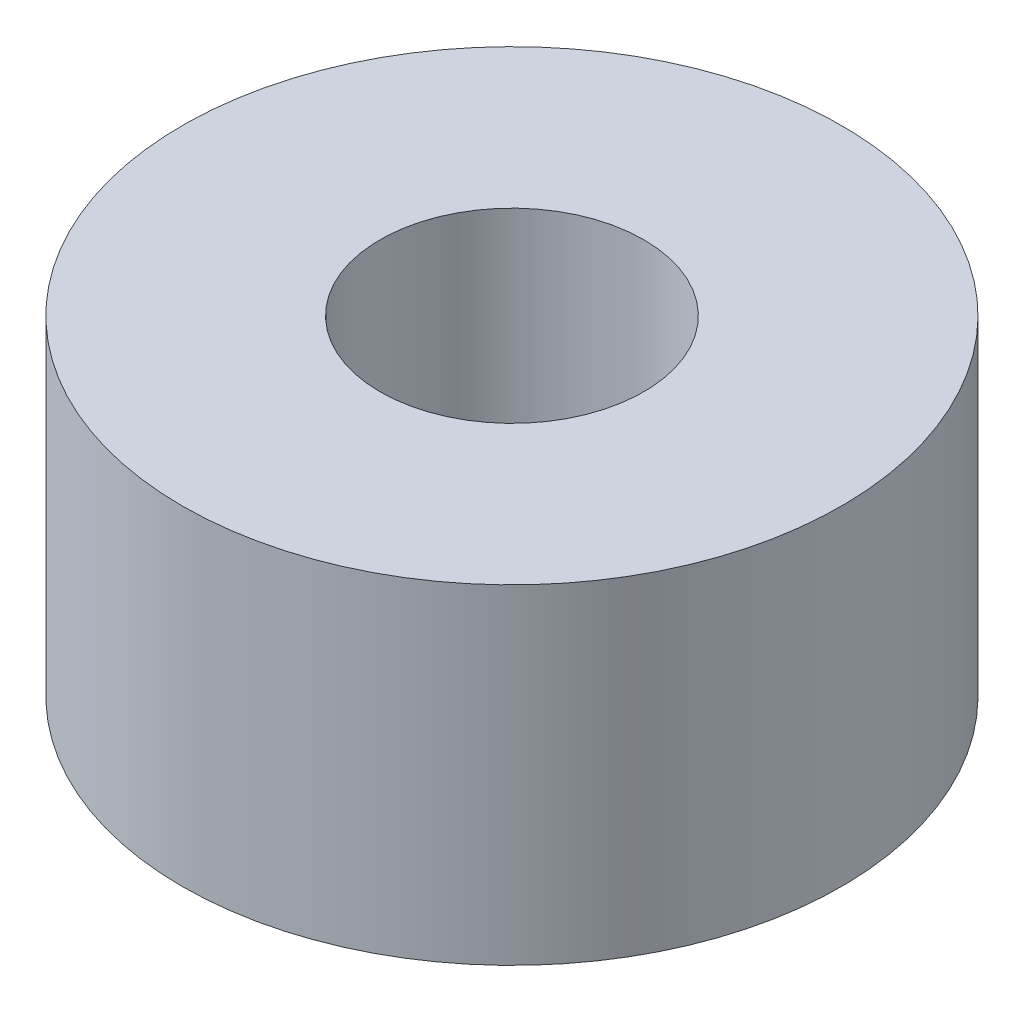
from build123d import *

# Parameters (mm, degrees)
SKETCH_1_R      = 2.5
SKETCH_1_R_2    = 1
EXTRUDE_1_DEPTH = 2.5


with BuildPart() as part:
    # 草图1 → 凸台-拉伸1 (new body)
    with BuildSketch(Plane(origin=(0, 0, 0), x_dir=(1, 0, 0), z_dir=(0, 1, 0))):
        Circle(SKETCH_1_R)
        Circle(SKETCH_1_R_2, mode=Mode.SUBTRACT)
    extrude(amount=EXTRUDE_1_DEPTH)


solid = part.part
